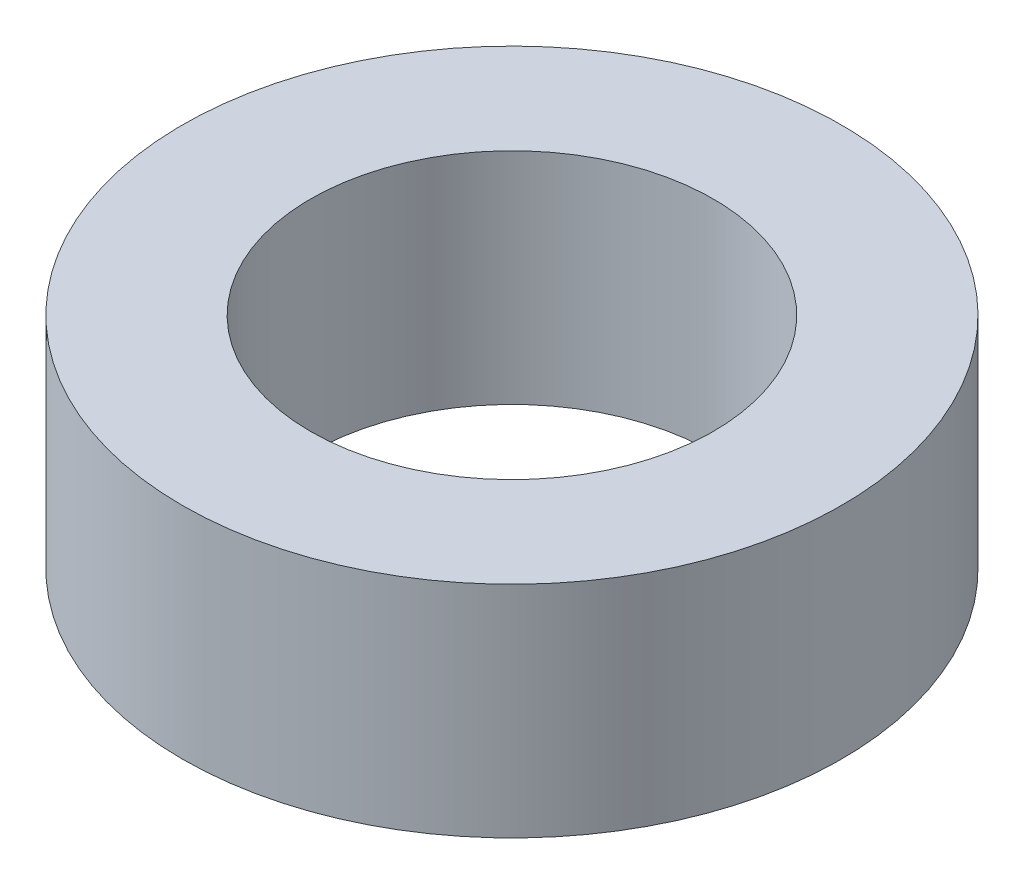
from build123d import *

# Parameters (mm, degrees)
SKETCH1_R           = 4.5
SKETCH1_R_2         = 2.75
BOSS_EXTRUDE1_DEPTH = 3


with BuildPart() as part:
    # Sketch1 → Boss-Extrude1 (new body)
    with BuildSketch(Plane(origin=(0, 0, 0), x_dir=(1, 0, 0), z_dir=(0, 1, 0))):
        Circle(SKETCH1_R)
        Circle(SKETCH1_R_2, mode=Mode.SUBTRACT)
    extrude(amount=BOSS_EXTRUDE1_DEPTH)


solid = part.part
